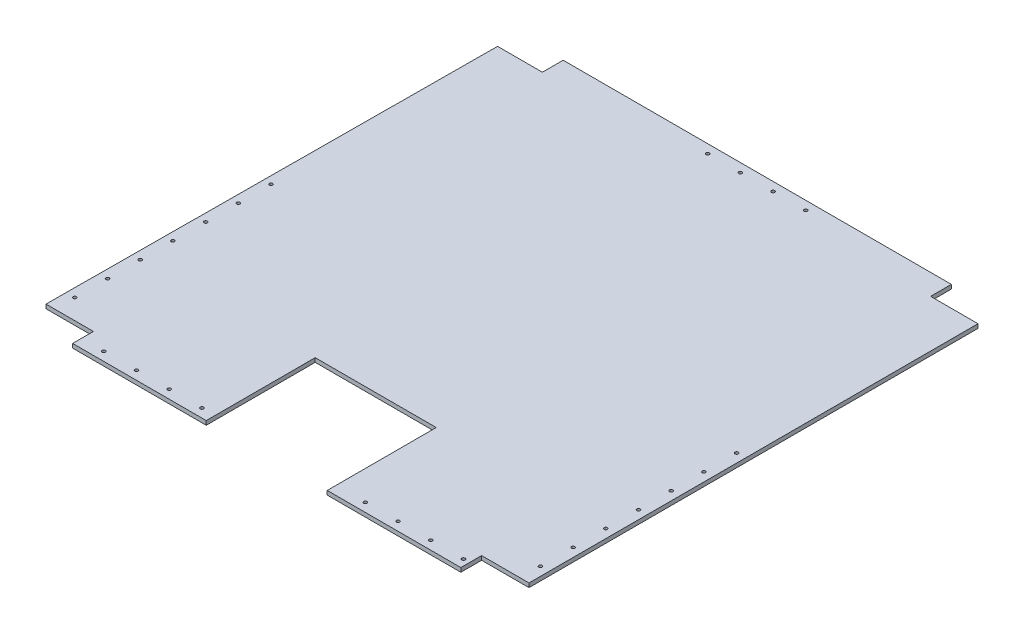
from build123d import *

# Parameters (mm, degrees)
BOSS_EXTRUDE1_DEPTH = 5
SKETCH2_R           = 2
CUT_EXTRUDE1_DEPTH  = 6


with BuildPart() as part:
    # Sketch1 → Boss-Extrude1 (new body)
    with BuildSketch(Plane(origin=(0, 329.925662842, 0), x_dir=(1, 0, 0), z_dir=(0, 1, 0))):
        Polygon((507.724872759, 70.717280325), (507.724872759, 45.317280325), (565.699872759, 45.317280325), (565.699872759, -503.882719675), (507.724872759, -503.882719675), (507.724872759, -529.282719675), (344.299872759, -529.282719675), (344.299872759, -396.017719675), (196.299872759, -396.017719675), (196.299872759, -529.282719675), (32.874872759, -529.282719675), (32.874872759, -503.882719675), (-25.100127241, -503.882719675), (-21.925127241, 45.317280325), (32.874872759, 45.317280325), (32.874872759, 70.717280325), align=None)
    extrude(amount=BOSS_EXTRUDE1_DEPTH)

    # Sketch2 → Cut-Extrude1 (cut, through all)
    with BuildSketch(Plane.XZ.offset(-329.925662842)):
        with Locations((60.299872759, 518.607719675)):
            Circle(SKETCH2_R)
        with Locations((380.299872759, 518.607719675)):
            Circle(SKETCH2_R)
        with Locations((220.299872759, -60.042280325)):
            Circle(SKETCH2_R)
        with Locations((100.299872759, 518.607719675)):
            Circle(SKETCH2_R)
        with Locations((420.299872759, 518.607719675)):
            Circle(SKETCH2_R)
        with Locations((260.299872759, -60.042280325)):
            Circle(SKETCH2_R)
        with Locations((140.299872759, 518.607719675)):
            Circle(SKETCH2_R)
        with Locations((460.299872759, 518.607719675)):
            Circle(SKETCH2_R)
        with Locations((300.299872759, -60.042280325)):
            Circle(SKETCH2_R)
        with Locations((180.299872759, 518.607719675)):
            Circle(SKETCH2_R)
        with Locations((500.299872759, 518.607719675)):
            Circle(SKETCH2_R)
        with Locations((340.299872759, -60.042280325)):
            Circle(SKETCH2_R)
        with Locations((-14.425127241, 239.282719675)):
            Circle(SKETCH2_R)
        with Locations((555.024872759, 239.282719675)):
            Circle(SKETCH2_R)
        with Locations((-14.425127241, 279.282719675)):
            Circle(SKETCH2_R)
        with Locations((555.024872759, 279.282719675)):
            Circle(SKETCH2_R)
        with Locations((-14.425127241, 319.282719675)):
            Circle(SKETCH2_R)
        with Locations((555.024872759, 319.282719675)):
            Circle(SKETCH2_R)
        with Locations((-14.425127241, 359.282719675)):
            Circle(SKETCH2_R)
        with Locations((555.024872759, 359.282719675)):
            Circle(SKETCH2_R)
        with Locations((-14.425127241, 399.282719675)):
            Circle(SKETCH2_R)
        with Locations((555.024872759, 399.282719675)):
            Circle(SKETCH2_R)
        with Locations((-14.425127241, 439.282719675)):
            Circle(SKETCH2_R)
        with Locations((555.024872759, 439.282719675)):
            Circle(SKETCH2_R)
        with Locations((-14.425127241, 479.282719675)):
            Circle(SKETCH2_R)
        with Locations((555.024872759, 479.282719675)):
            Circle(SKETCH2_R)
    extrude(amount=-CUT_EXTRUDE1_DEPTH, mode=Mode.SUBTRACT)


solid = part.part
